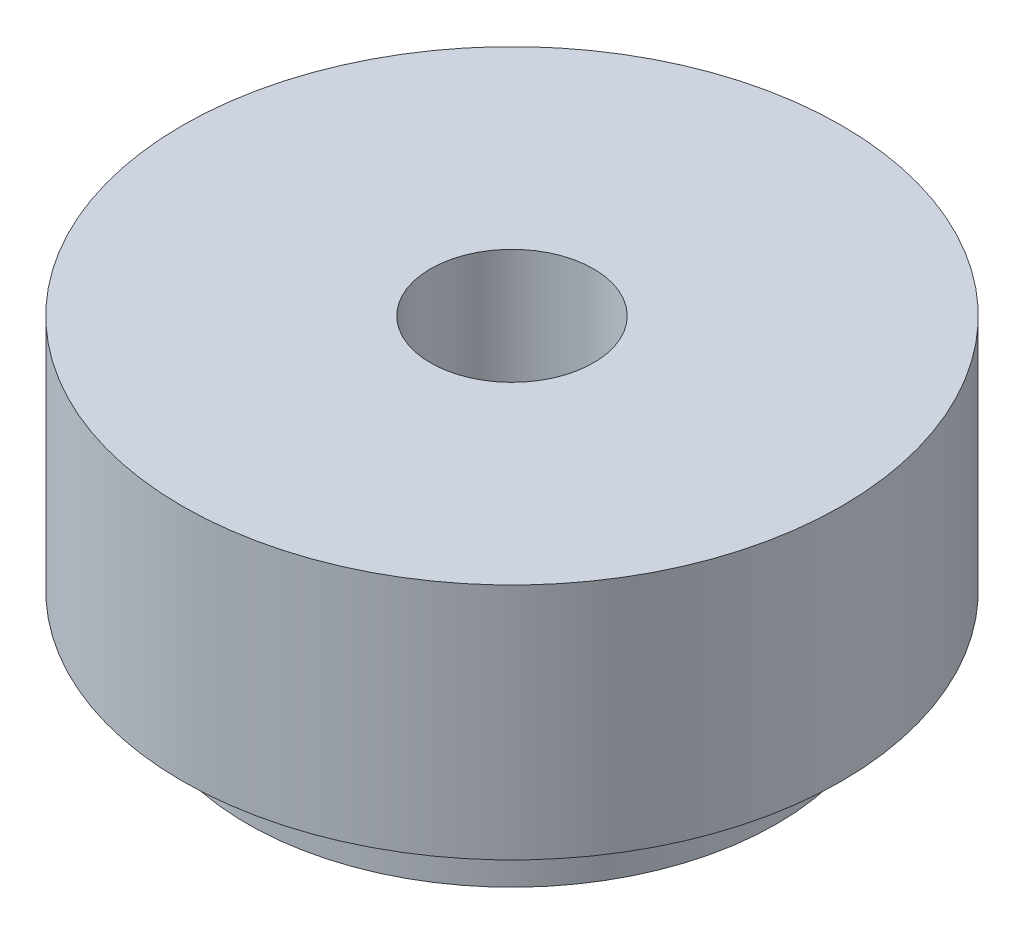
from build123d import *


with BuildPart() as part:
    # Sketch1 → Revolve1 (revolve)
    with BuildSketch(Plane.XY, mode=Mode.PRIVATE) as revolve1_sk:
        Polygon((3.6703, 0), (4.572, 0), (4.572, 3.302), (1.1303, 3.302), (1.1303, -0.9652), (3.6703, -0.9652), align=None)
    revolve(revolve1_sk.sketch.rotate(Axis((0, 57.743737076, 0), (0, -1, 0)), 180), axis=Axis((0, 57.743737076, 0), (0, -1, 0)))  # turned: the seam where the file's is


solid = part.part
